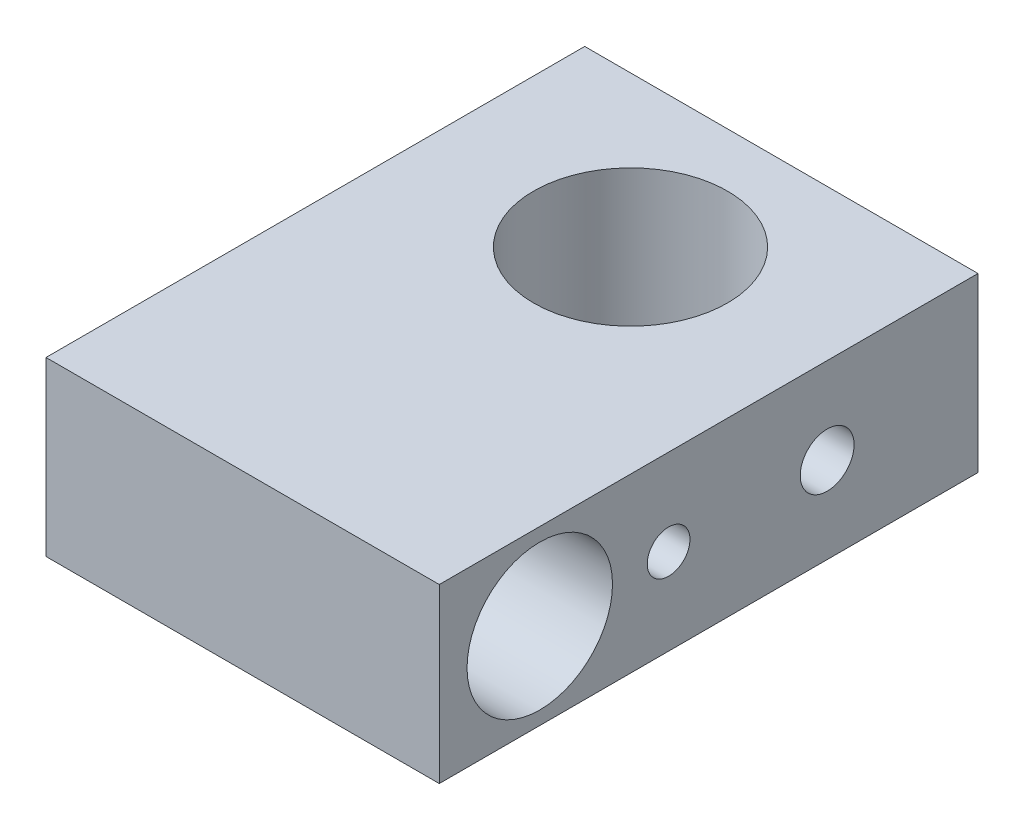
from build123d import *

# Parameters (mm, degrees)
SKETCH1_W                 = 18.25
SKETCH1_H                 = 25
BOSS_EXTRUDE1_DEPTH       = 8
M10X1_0_TAPPED_HOLE1_D    = 9
SKETCH7_R                 = 3.375
SKETCH7_R_2               = 0.9906
CUT_EXTRUDE2_DEPTH        = 19.25
M3X0_5_TAPPED_HOLE1_D     = 2.5
M3X0_5_TAPPED_HOLE1_DEPTH = 6.35
M3X0_5_TAPPED_HOLE1_TIP   = 0.751075774


with BuildPart() as part:
    # Sketch1 → Boss-Extrude1 (new body)
    with BuildSketch(Plane(origin=(0, 0, 0), x_dir=(1, 0, 0), z_dir=(0, 1, 0))):
        with Locations((0, -5.5)):
            Rectangle(SKETCH1_W, SKETCH1_H)
    extrude(amount=BOSS_EXTRUDE1_DEPTH)

    # M10x1.0 Tapped Hole1 (through all)
    with Locations(Plane(origin=(0, 8, 0), x_dir=(-1, 0, 0), z_dir=(0, 1, 0))):
        with Locations((0, 0)):
            Hole(M10X1_0_TAPPED_HOLE1_D / 2)

    # Sketch7 → Cut-Extrude2 (cut, through all)
    with BuildSketch(Plane(origin=(9.125, 0, 0), x_dir=(0, 0, -1), z_dir=(1, 0, 0))):
        with Locations((-13.336186812, 4)):
            Circle(SKETCH7_R)
        with Locations((-7.3575, 4)):
            Circle(SKETCH7_R_2)
    extrude(amount=-CUT_EXTRUDE2_DEPTH, mode=Mode.SUBTRACT)

    # M3x0.5 Tapped Hole1
    with Locations(Plane(origin=(9.125, 0, 0), x_dir=(0, 0, -1), z_dir=(1, 0, 0))):
        with Locations((0, 4)):
            Hole(M3X0_5_TAPPED_HOLE1_D / 2, depth=M3X0_5_TAPPED_HOLE1_DEPTH)
            with Locations((0, 0, -(M3X0_5_TAPPED_HOLE1_DEPTH + M3X0_5_TAPPED_HOLE1_TIP / 2))):  # 118° drill point
                Cone(0, M3X0_5_TAPPED_HOLE1_D / 2, M3X0_5_TAPPED_HOLE1_TIP, mode=Mode.SUBTRACT)


solid = part.part
